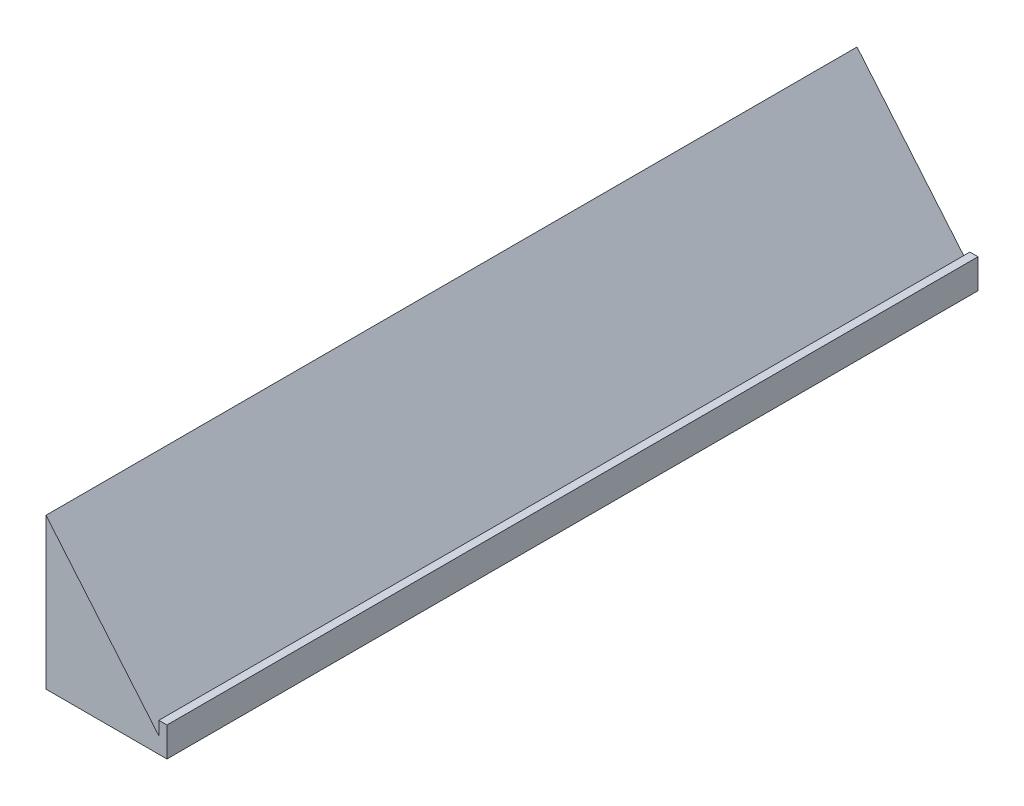
from build123d import *

# Parameters (mm, degrees)
BOSS_EXTRUDE1_DEPTH = 300


with BuildPart() as part:
    # Sketch3 → Boss-Extrude1 (new body)
    with BuildSketch(Plane.XY):
        Polygon((0, 0), (0, 50), (41.747130959, 0.178548228), (41.747130959, 5.178548228), (44.747130959, 5.178548228), (44.747130959, -5.72815534), (0, -5.72815534), align=None)
    extrude(amount=BOSS_EXTRUDE1_DEPTH)


solid = part.part
